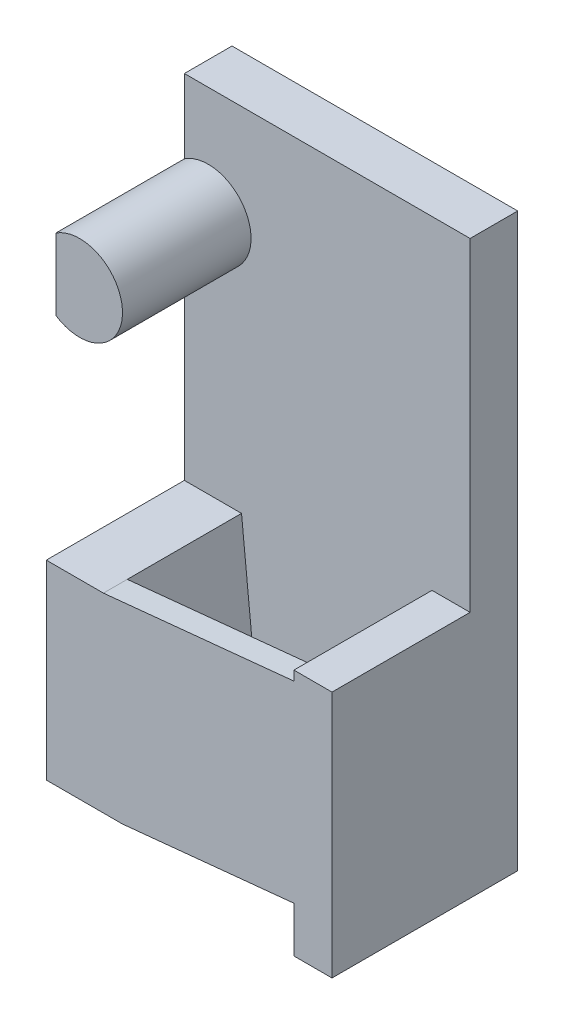
from build123d import *

# Parameters (mm, degrees)
SKETCH1_W           = 60
SKETCH1_H           = 120
BOSS_EXTRUDE1_DEPTH = 10
SKETCH3_R           = 9
BOSS_EXTRUDE3_DEPTH = 27
CUT_EXTRUDE1_DEPTH  = 38
SKETCH5_W           = 16
SKETCH5_H           = 40
BOSS_EXTRUDE4_DEPTH = 29
SKETCH2_W           = 8
SKETCH2_H           = 52
BOSS_EXTRUDE5_DEPTH = 29
CUT_EXTRUDE2_DEPTH  = 29
SKETCH9_W           = 5
SKETCH9_H           = 40.199502484
BOSS_EXTRUDE6_DEPTH = 42


with BuildPart() as part:
    # Sketch1 → Boss-Extrude1 (new body)
    with BuildSketch(Plane.XY):
        with Locations((30, 60)):
            Rectangle(SKETCH1_W, SKETCH1_H)
    extrude(amount=BOSS_EXTRUDE1_DEPTH)

    # Sketch3 → Boss-Extrude3 (add)
    with BuildSketch(Plane.XY.offset(10)):
        with Locations((5, 97)):
            Circle(SKETCH3_R)
    extrude(amount=BOSS_EXTRUDE3_DEPTH)

    # Sketch4 → Cut-Extrude1 (cut, through all)
    with BuildSketch(Plane.XY.offset(37)):
        Polygon((0, 104.483314774), (0, 89.516685226), (-21.075421501, 89.516685226), (-21.075421501, 106.99834991), align=None)
    extrude(amount=-CUT_EXTRUDE1_DEPTH, mode=Mode.SUBTRACT)

    # Sketch5 → Boss-Extrude4 (add)
    with BuildSketch(Plane.XY.offset(10)):
        with Locations((8, 26)):
            Rectangle(SKETCH5_W, SKETCH5_H)
    extrude(amount=BOSS_EXTRUDE4_DEPTH)

    # Sketch2 → Boss-Extrude5 (add)
    with BuildSketch(Plane.XY.offset(10)):
        with Locations((56, 26)):
            Rectangle(SKETCH2_W, SKETCH2_H)
    extrude(amount=BOSS_EXTRUDE5_DEPTH)

    # Sketch8 → Cut-Extrude2 (cut)
    with BuildSketch(Plane.XY.offset(39)):
        Polygon((16, 46), (12, 46), (16, 6), align=None)
    extrude(amount=-CUT_EXTRUDE2_DEPTH, mode=Mode.SUBTRACT)

    # Sketch9 → Boss-Extrude6 (add)
    with BuildSketch(Plane(origin=(16.435643564, 1.643564356, 0), x_dir=(0, 0, -1), z_dir=(0.99503719, 0.099503719, 0))):
        with Locations((-36.5, 24.477914879)):
            Rectangle(SKETCH9_W, SKETCH9_H)
    extrude(amount=BOSS_EXTRUDE6_DEPTH)


solid = part.part
